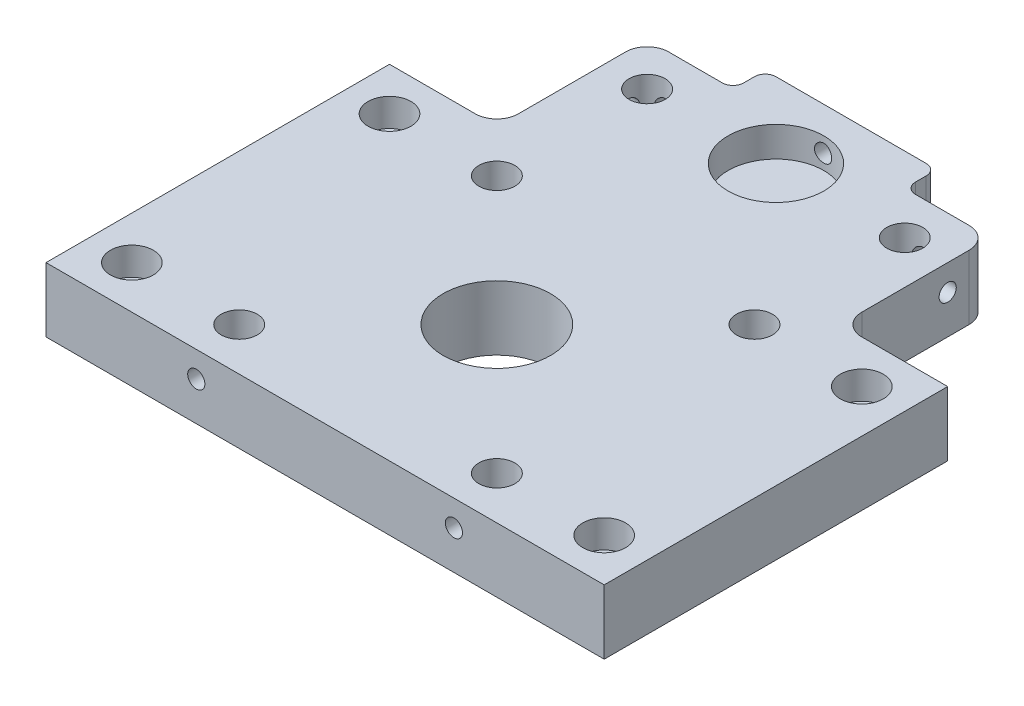
from build123d import *

# Parameters (mm, degrees)
ESBO_O1_W                = 130
ESBO_O1_H                = 130
RESSALTO_EXTRUS_O1_DEPTH = 15
ESBO_O2_R                = 4.2
CORTE_EXTRUS_O1_DEPTH    = 12
ESBO_O3_R                = 12.5
CORTE_EXTRUS_O2_DEPTH    = 16
ESBO_O4_R                = 11.15
CORTE_EXTRUS_O3_DEPTH    = 7
ESBO_O5_W                = 25
ESBO_O5_H                = 50
CORTE_EXTRUS_O4_DEPTH    = 16
FILETE1_R                = 5
ESBO_O6_R                = 5
CORTE_EXTRUS_O5_DEPTH    = 6.5
ESBO_O7_R                = 3
CORTE_EXTRUS_O6_DEPTH    = 9.5
ESBO_O8_W                = 15
ESBO_O8_H                = 15
CORTE_EXTRUS_O7_DEPTH    = 16
ESBO_O9_R                = 2
CORTE_EXTRUS_O8_DEPTH    = 10
ESBO_O10_R               = 2
CORTE_EXTRUS_O9_DEPTH    = 10
ESBO_O11_R               = 2
CORTE_EXTRUS_O10_DEPTH   = 10
ESBO_O12_R               = 2
CORTE_EXTRUS_O11_DEPTH   = 10
FILETE2_R                = 5
CORTE_EXTRUS_O12_DEPTH   = 16
ESBO_O14_R               = 2
CORTE_EXTRUS_O13_DEPTH   = 10
FILETE4_R                = 5
FILETE5_R                = 2.5


with BuildPart() as part:
    # Esboço1 → Ressalto-extrusão1 (new body)
    with BuildSketch(Plane(origin=(0, 0, 0), x_dir=(1, 0, 0), z_dir=(0, 1, 0))):
        Rectangle(ESBO_O1_W, ESBO_O1_H)
    extrude(amount=RESSALTO_EXTRUS_O1_DEPTH)

    # Esboço2 → Corte-extrusão1 (cut)
    with BuildSketch(Plane(origin=(0, 15, 0), x_dir=(1, 0, 0), z_dir=(0, 1, 0))):
        with Locations((-30, 5)):
            Circle(ESBO_O2_R)
        with Locations((30, 5)):
            Circle(ESBO_O2_R)
        with Locations((30, -55)):
            Circle(ESBO_O2_R)
        with Locations((-30, -55)):
            Circle(ESBO_O2_R)
        with Locations((-30, 40)):
            Circle(ESBO_O2_R)
        with Locations((30, 40)):
            Circle(ESBO_O2_R)
    extrude(amount=-CORTE_EXTRUS_O1_DEPTH, mode=Mode.SUBTRACT)

    # Esboço3 → Corte-extrusão2 (cut, through all)
    with BuildSketch(Plane(origin=(0, 15, 0), x_dir=(1, 0, 0), z_dir=(0, 1, 0))):
        with Locations((0, -25)):
            Circle(ESBO_O3_R)
    extrude(amount=-CORTE_EXTRUS_O2_DEPTH, mode=Mode.SUBTRACT)

    # Esboço4 → Corte-extrusão3 (cut)
    with BuildSketch(Plane(origin=(0, 15, 0), x_dir=(1, 0, 0), z_dir=(0, 1, 0))):
        with Locations((0, 40)):
            Circle(ESBO_O4_R)
    extrude(amount=-CORTE_EXTRUS_O3_DEPTH, mode=Mode.SUBTRACT)

    # Esboço5 → Corte-extrusão4 (cut, through all)
    with BuildSketch(Plane(origin=(0, 15, 0), x_dir=(1, 0, 0), z_dir=(0, 1, 0))):
        with Locations((-52.5, 40)):
            Rectangle(ESBO_O5_W, ESBO_O5_H)
        with Locations((52.5, 40)):
            Rectangle(ESBO_O5_W, ESBO_O5_H)
    extrude(amount=-CORTE_EXTRUS_O4_DEPTH, mode=Mode.SUBTRACT)

    # Filete1
    filete1_edges = [part.edges().sort_by_distance(p)[0] for p in [
        (-40, 7.5, -65),
        (40, 7.5, -65),
    ]]
    fillet(filete1_edges, radius=FILETE1_R)

    # Esboço6 → Corte-extrusão5 (cut)
    with BuildSketch(Plane(origin=(0, 15, 0), x_dir=(1, 0, 0), z_dir=(0, 1, 0))):
        with Locations((-55, 5)):
            Circle(ESBO_O6_R)
        with Locations((55, 5)):
            Circle(ESBO_O6_R)
        with Locations((55, -55)):
            Circle(ESBO_O6_R)
        with Locations((-55, -55)):
            Circle(ESBO_O6_R)
    extrude(amount=-CORTE_EXTRUS_O5_DEPTH, mode=Mode.SUBTRACT)

    # Esboço7 → Corte-extrusão6 (cut, through all)
    with BuildSketch(Plane(origin=(0, 8.5, 0), x_dir=(1, 0, 0), z_dir=(0, 1, 0))):
        with Locations((-55, 5)):
            Circle(ESBO_O7_R)
        with Locations((55, 5)):
            Circle(ESBO_O7_R)
        with Locations((55, -55)):
            Circle(ESBO_O7_R)
        with Locations((-55, -55)):
            Circle(ESBO_O7_R)
    extrude(amount=-CORTE_EXTRUS_O6_DEPTH, mode=Mode.SUBTRACT)

    # Esboço8 → Corte-extrusão7 (cut, through all)
    with BuildSketch(Plane(origin=(0, 15, 0), x_dir=(1, 0, 0), z_dir=(0, 1, 0))):
        with Locations((0, 65)):
            Rectangle(ESBO_O8_W, ESBO_O8_H)
    extrude(amount=-CORTE_EXTRUS_O7_DEPTH, mode=Mode.SUBTRACT)

    # Esboço9 → Corte-extrusão8 (cut)
    with BuildSketch(Plane(origin=(0, 0, -57.5), x_dir=(-1, 0, 0), z_dir=(0, 0, -1))):
        with Locations((0, 11.5)):
            Circle(ESBO_O9_R)
    extrude(amount=-CORTE_EXTRUS_O8_DEPTH, mode=Mode.SUBTRACT)

    # Esboço10 → Corte-extrusão9 (cut)
    with BuildSketch(Plane.ZY.offset(40)):
        with Locations((-40, 9)):
            Circle(ESBO_O10_R)
    extrude(amount=-CORTE_EXTRUS_O9_DEPTH, mode=Mode.SUBTRACT)

    # Esboço11 → Corte-extrusão10 (cut)
    with BuildSketch(Plane(origin=(40, 0, 0), x_dir=(0, 0, -1), z_dir=(1, 0, 0))):
        with Locations((40, 9)):
            Circle(ESBO_O11_R)
    extrude(amount=-CORTE_EXTRUS_O10_DEPTH, mode=Mode.SUBTRACT)

    # Esboço12 → Corte-extrusão11 (cut)
    with BuildSketch(Plane.XY.offset(65)):
        with Locations((-30, 9)):
            Circle(ESBO_O12_R)
        with Locations((30, 9)):
            Circle(ESBO_O12_R)
    extrude(amount=-CORTE_EXTRUS_O11_DEPTH, mode=Mode.SUBTRACT)

    # Filete2
    filete2_edges = [part.edges().sort_by_distance(p)[0] for p in [
        (-40, 7.5, -15),
        (40, 7.5, -15),
    ]]
    fillet(filete2_edges, radius=FILETE2_R)

    # Esboço13 → Corte-extrusão12 (cut, through all)
    with BuildSketch(Plane(origin=(0, 15, 0), x_dir=(1, 0, 0), z_dir=(0, 1, 0))):
        Polygon((-7.5, 57.5), (-20, 57.5), (-20, 50), (-40, 50), (-40, 57.5), (-40, 65), (-7.5, 65), align=None)
        Polygon((7.5, 57.5), (7.5, 65), (40, 65), (40, 57.5), (40, 50), (20, 50), (20, 57.5), align=None)
    extrude(amount=-CORTE_EXTRUS_O12_DEPTH, mode=Mode.SUBTRACT)

    # Esboço14 → Corte-extrusão13 (cut)
    with BuildSketch(Plane(origin=(0, 0, -50), x_dir=(-1, 0, 0), z_dir=(0, 0, -1))):
        with Locations((-30, 9)):
            Circle(ESBO_O14_R)
        with Locations((30, 9)):
            Circle(ESBO_O14_R)
    extrude(amount=-CORTE_EXTRUS_O13_DEPTH, mode=Mode.SUBTRACT)

    # Filete4
    filete4_edges = [part.edges().sort_by_distance(p)[0] for p in [
        (-40, 7.5, -50),
        (40, 7.5, -50),
    ]]
    fillet(filete4_edges, radius=FILETE4_R)

    # Filete5
    filete5_edges = [part.edges().sort_by_distance(p)[0] for p in [
        (-20, 7.5, -57.5),
        (-20, 7.5, -50),
        (20, 7.5, -57.5),
        (20, 7.5, -50),
    ]]
    fillet(filete5_edges, radius=FILETE5_R)


solid = part.part
